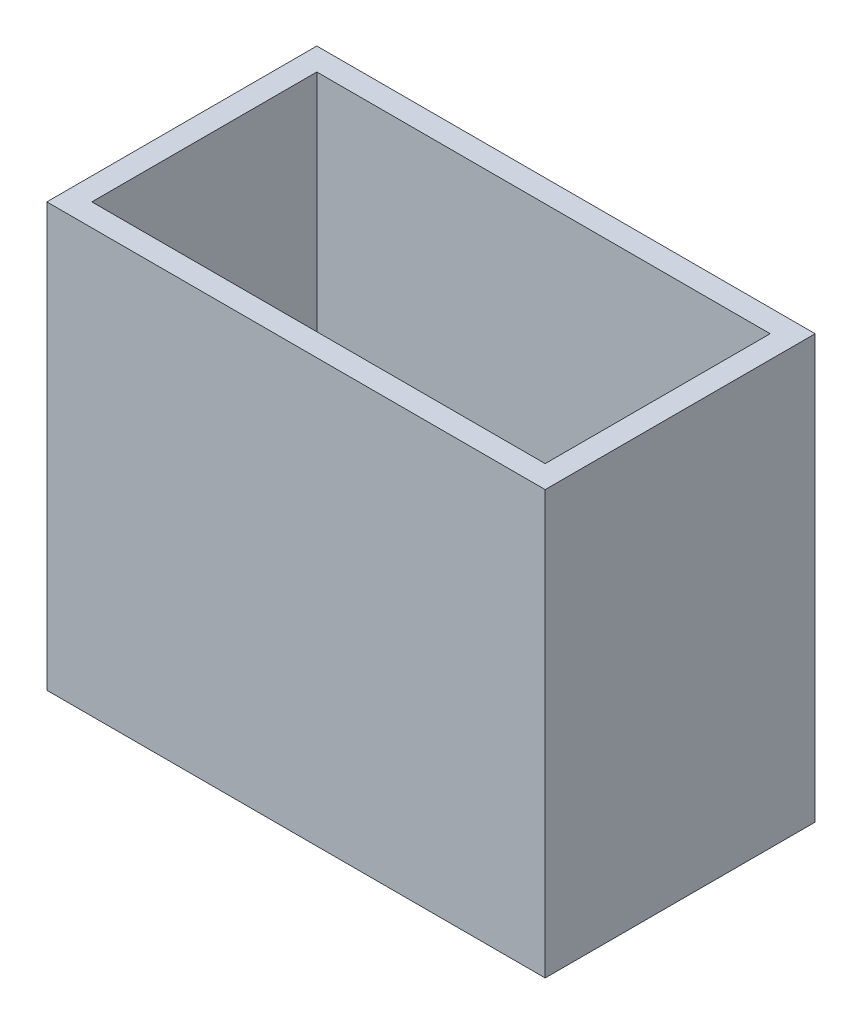
from build123d import *

# Parameters (mm, degrees)
SKETCH_1_W          = 44.3
SKETCH_1_H          = 37.6
EXTRUDE_1_DEPTH     = 24
SKETCH_2_W          = 40.3
SKETCH_2_H          = 20
CUT_EXTRUDE_1_DEPTH = 36.6


with BuildPart() as part:
    # 草图1 → 凸台-拉伸1 (new body)
    with BuildSketch(Plane.XY):
        with Locations((22.15, 18.8)):
            Rectangle(SKETCH_1_W, SKETCH_1_H)
    extrude(amount=EXTRUDE_1_DEPTH)

    # 草图2 → 切除-拉伸1 (cut)
    with BuildSketch(Plane(origin=(0, 37.6, 0), x_dir=(1, 0, 0), z_dir=(0, 1, 0))):
        with Locations((22.15, -12)):
            Rectangle(SKETCH_2_W, SKETCH_2_H)
    extrude(amount=-CUT_EXTRUDE_1_DEPTH, mode=Mode.SUBTRACT)


solid = part.part
